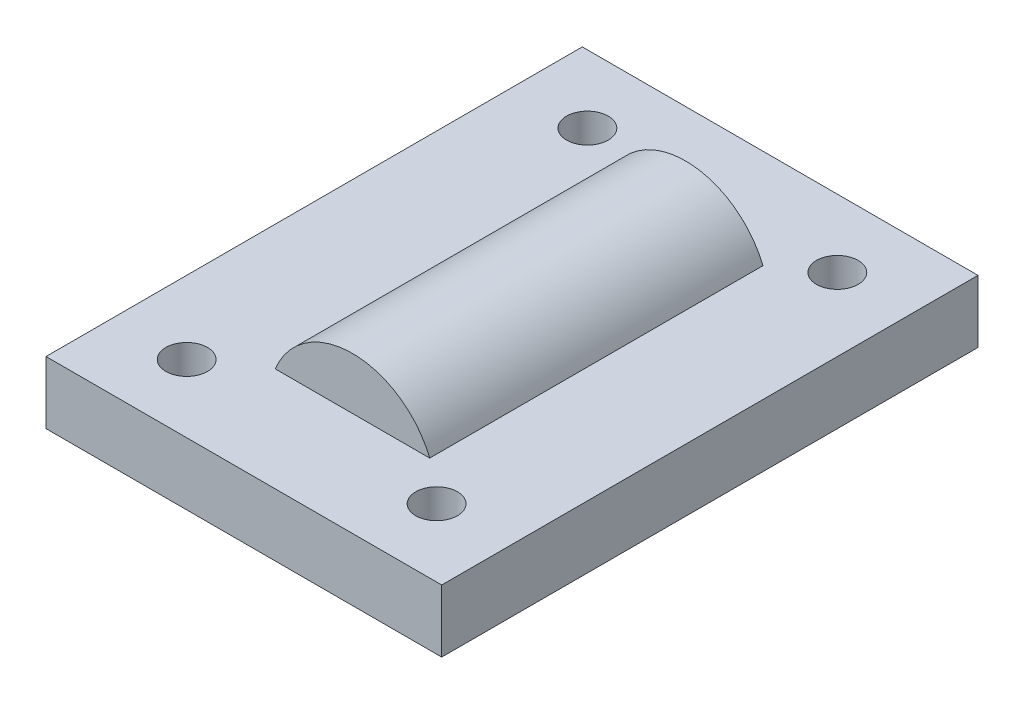
from build123d import *

# Parameters (mm, degrees)
CROQUIS1_W                   = 19
CROQUIS1_H                   = 25.75
CROQUIS1_R                   = 1.000000029
CROQUIS1_R_2                 = 0.999999792
CROQUIS1_R_3                 = 1.000000052
CROQUIS1_R_4                 = 1.000000059
SALIENTE_EXTRUIR1_DEPTH      = 3
SALIENTE_EXTRUIR2_DEPTH      = 8
SALIENTE_EXTRUIR2_DEPTH_BACK = 8


with BuildPart() as part:
    # Croquis1 → Saliente-Extruir1 (new body)
    with BuildSketch(Plane(origin=(0, 0, 0), x_dir=(1, 0, 0), z_dir=(0, 1, 0))):
        with Locations((-0.226911439, -0.113455719)):
            Rectangle(CROQUIS1_W, CROQUIS1_H)
        with Locations((-6.226911361, 9.506544208)):
            Circle(CROQUIS1_R, mode=Mode.SUBTRACT)
        with Locations((5.773088267, 9.506544313)):
            Circle(CROQUIS1_R_2, mode=Mode.SUBTRACT)
        with Locations((5.773088494, -9.733455829)):
            Circle(CROQUIS1_R_3, mode=Mode.SUBTRACT)
        with Locations((-6.226911268, -9.733455698)):
            Circle(CROQUIS1_R_4, mode=Mode.SUBTRACT)
    extrude(amount=SALIENTE_EXTRUIR1_DEPTH)

    # Croquis2 → Saliente-Extruir2 (add, two sides)
    with BuildSketch(Plane.XY) as saliente_extruir2_sk:
        with BuildLine():
            Line((-3.708099244, 3), (3.708099244, 3))
            ThreePointArc((3.708099244, 3), (0, 5.5), (-3.708099244, 3))
        make_face()
    extrude(amount=SALIENTE_EXTRUIR2_DEPTH)
    extrude(saliente_extruir2_sk.sketch, amount=-SALIENTE_EXTRUIR2_DEPTH_BACK)


solid = part.part
